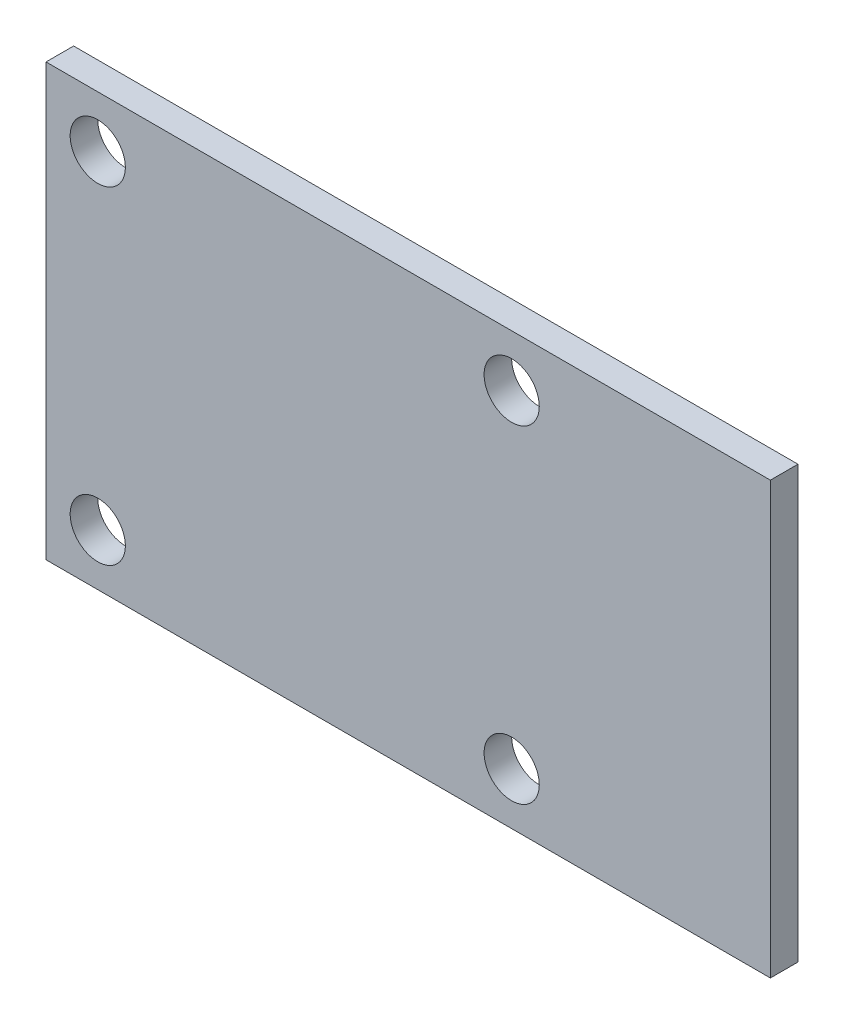
from build123d import *

# Parameters (mm, degrees)
SKETCH_1_W          = 42
SKETCH_1_H          = 25
EXTRUDE_1_DEPTH     = 1.6
SKETCH_2_R          = 1.6
CUT_EXTRUDE_1_DEPTH = 1.6


with BuildPart() as part:
    # 草图1 → 凸台-拉伸1 (new body)
    with BuildSketch(Plane.XY):
        Rectangle(SKETCH_1_W, SKETCH_1_H)
    extrude(amount=EXTRUDE_1_DEPTH)

    # 草图2 → 切除-拉伸1 (cut)
    with BuildSketch(Plane.XY.offset(1.6)):
        with Locations((-18, 9.5)):
            Circle(SKETCH_2_R)
        with Locations((-18, -9.5)):
            Circle(SKETCH_2_R)
        with Locations((6, 9.5)):
            Circle(SKETCH_2_R)
        with Locations((6, -9.5)):
            Circle(SKETCH_2_R)
    extrude(amount=-CUT_EXTRUDE_1_DEPTH, mode=Mode.SUBTRACT)


solid = part.part
